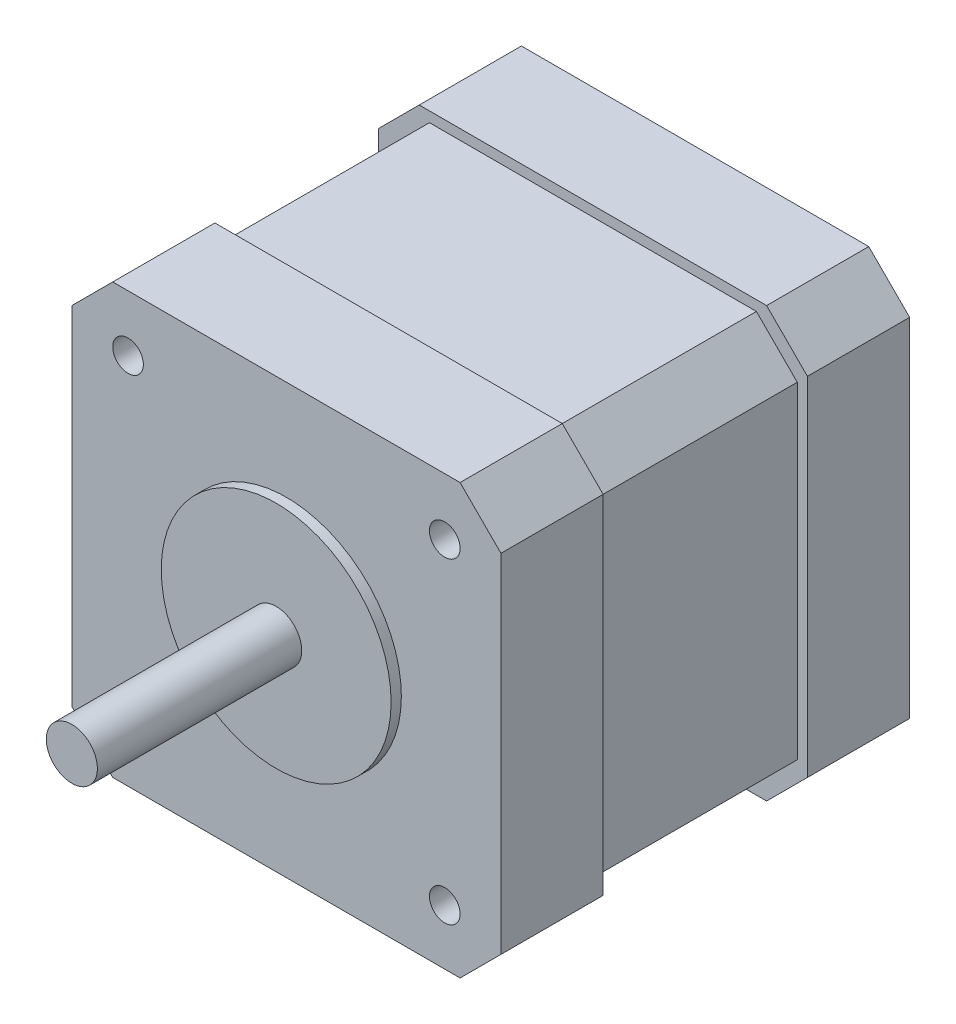
from build123d import *

# Parameters (mm, degrees)
SKETCH1_W           = 42
SKETCH1_H           = 42
BOSS_EXTRUDE1_DEPTH = 10
SKETCH2_W           = 40
SKETCH2_H           = 40
BOSS_EXTRUDE2_DEPTH = 20
SKETCH3_W           = 42
SKETCH3_H           = 42
BOSS_EXTRUDE3_DEPTH = 10
SKETCH4_R           = 11.25
BOSS_EXTRUDE4_DEPTH = 1
CHAMFER1_SIZE       = 4
SKETCH5_R           = 2.5
BOSS_EXTRUDE5_DEPTH = 20
SKETCH6_R           = 1.5
CUT_EXTRUDE1_DEPTH  = 40


with BuildPart() as part:
    # Sketch1 → Boss-Extrude1 (new body)
    with BuildSketch(Plane.XY):
        Rectangle(SKETCH1_W, SKETCH1_H)
    extrude(amount=BOSS_EXTRUDE1_DEPTH)

    # Sketch2 → Boss-Extrude2 (add)
    with BuildSketch(Plane.XY.offset(10)):
        Rectangle(SKETCH2_W, SKETCH2_H)
    extrude(amount=BOSS_EXTRUDE2_DEPTH)

    # Sketch3 → Boss-Extrude3 (add)
    with BuildSketch(Plane.XY.offset(30)):
        Rectangle(SKETCH3_W, SKETCH3_H)
    extrude(amount=BOSS_EXTRUDE3_DEPTH)

    # Sketch4 → Boss-Extrude4 (add)
    with BuildSketch(Plane.XY.offset(40)):
        Circle(SKETCH4_R)
    extrude(amount=BOSS_EXTRUDE4_DEPTH)

    # Chamfer1
    chamfer1_edges = [part.edges().sort_by_distance(p)[0] for p in [
        (20, -20, 20),
        (20, 20, 20),
        (-20, 20, 20),
        (-20, -20, 20),
        (21, -21, 35),
        (21, 21, 35),
        (-21, 21, 35),
        (-21, -21, 35),
        (21, -21, 5),
        (-21, -21, 5),
        (-21, 21, 5),
        (21, 21, 5),
    ]]
    chamfer(chamfer1_edges, length=CHAMFER1_SIZE)

    # Sketch5 → Boss-Extrude5 (add)
    with BuildSketch(Plane.XY.offset(41)):
        Circle(SKETCH5_R)
    extrude(amount=BOSS_EXTRUDE5_DEPTH)

    # Sketch6 → Cut-Extrude1 (cut)
    with BuildSketch(Plane.XY.offset(40)):
        with Locations((-15.5, -15.5)):
            Circle(SKETCH6_R)
        with Locations((-15.5, 15.5)):
            Circle(SKETCH6_R)
        with Locations((15.5, 15.417865976)):
            Circle(SKETCH6_R)
        with Locations((15.5, -15.582134024)):
            Circle(SKETCH6_R)
    extrude(amount=-CUT_EXTRUDE1_DEPTH, mode=Mode.SUBTRACT)


solid = part.part
